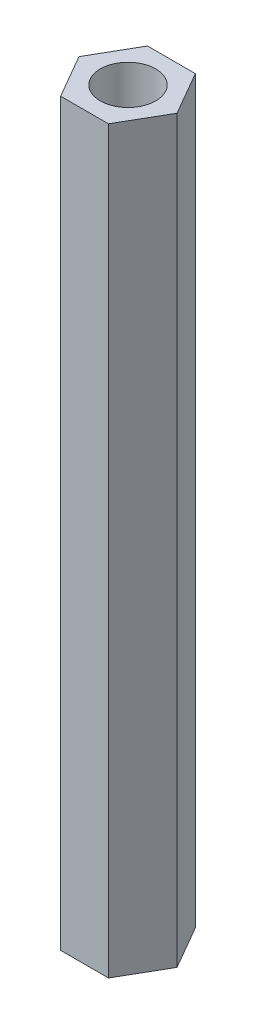
from build123d import *

# Parameters (mm, degrees)
SKETCH_1_R      = 1.5
EXTRUDE_1_DEPTH = 40


with BuildPart() as part:
    # 草图1 → 凸台-拉伸1 (new body)
    with BuildSketch(Plane(origin=(0, 0, 0), x_dir=(1, 0, 0), z_dir=(0, 1, 0))):
        Polygon((1.293226867, 2.35), (-1.293226867, 2.35), (-2.65, 0), (-1.293226867, -2.35), (1.293226867, -2.35), (2.65, 0), align=None)
        Circle(SKETCH_1_R, mode=Mode.SUBTRACT)
    extrude(amount=EXTRUDE_1_DEPTH)


solid = part.part
